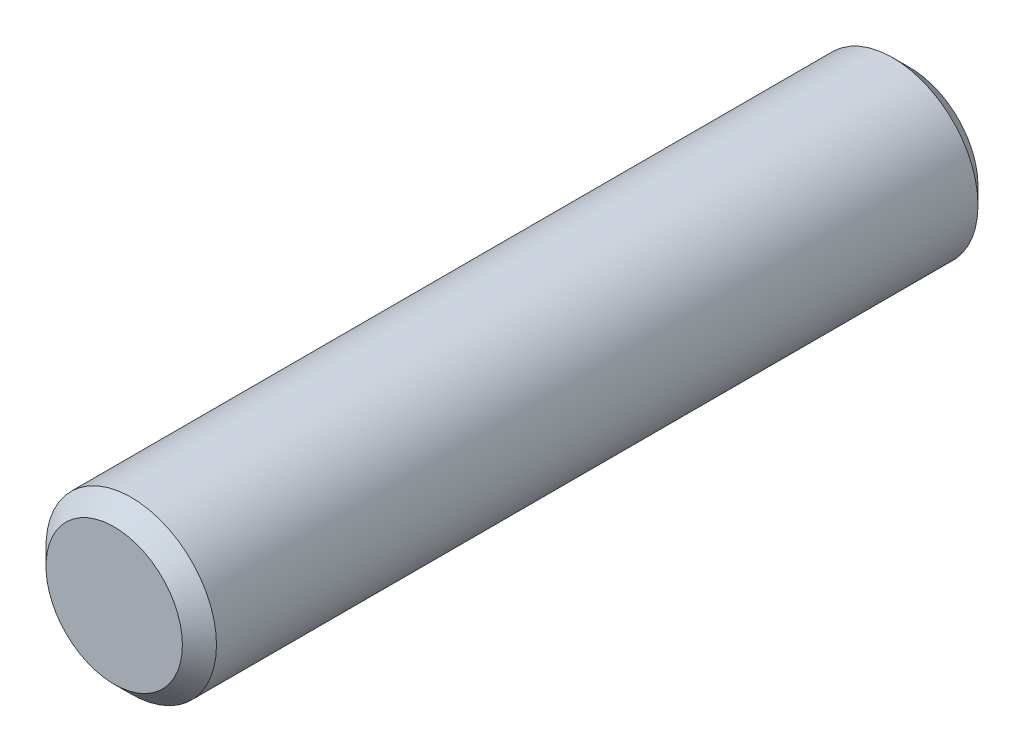
from build123d import *

# Parameters (mm, degrees)
SKETCH1_R           = 1.5
BOSS_EXTRUDE1_DEPTH = 7
CHAMFER1_SIZE       = 0.3


with BuildPart() as part:
    # Sketch1 → Boss-Extrude1 (new body, symmetric)
    with BuildSketch(Plane.XY):
        Circle(SKETCH1_R)
    extrude(amount=BOSS_EXTRUDE1_DEPTH, both=True)

    # Chamfer1
    chamfer1_edges = [part.edges().sort_by_distance(p)[0] for p in [
        (-1.5, 0, -7),
        (-1.5, 0, 7),
    ]]
    chamfer(chamfer1_edges, length=CHAMFER1_SIZE)


solid = part.part
